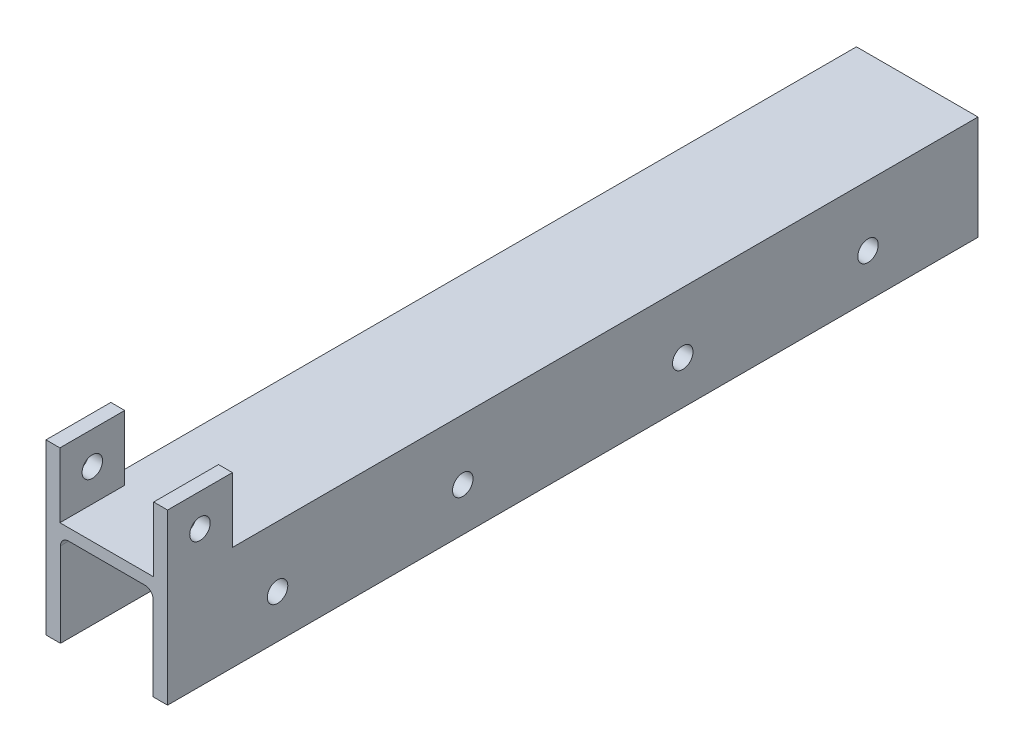
from build123d import *

# Parameters (mm, degrees)
BOSS_EXTRUDE2_DEPTH     = 177.8
SKETCH19_R              = 2.2479
CUT_EXTRUDE3_DEPTH      = 27.67
SKETCH21_W              = 3.048
SKETCH21_H              = 14.224
BOSS_EXTRUDE4_DEPTH     = 14.224
SKETCH22_R              = 2.2479
CUT_EXTRUDE4_DEPTH      = 24.622
CUT_EXTRUDE4_DEPTH_BACK = 4.048


with BuildPart() as part:
    # Sketch2 → Boss-Extrude2 (new body)
    with BuildSketch(Plane.XY):
        with BuildLine():
            Line((0, 0), (0, 22.86))
            Line((0, 22.86), (26.67, 22.86))
            Line((26.67, 22.86), (26.67, 0))
            Line((26.67, 0), (23.495, 0))
            Line((23.495, 0), (23.495, 18.542))
            ThreePointArc((23.495, 18.542), (22.974235857, 19.799235857), (21.717, 20.32))
            Line((21.717, 20.32), (4.953, 20.32))
            ThreePointArc((4.953, 20.32), (3.695764143, 19.799235857), (3.175, 18.542))
            Line((3.175, 18.542), (3.175, 0))
            Line((3.175, 0), (0, 0))
        make_face()
    extrude(amount=-BOSS_EXTRUDE2_DEPTH)

    # Sketch19 → Cut-Extrude3 (cut, through all)
    with BuildSketch(Plane(origin=(0, 0, 0), x_dir=(0, 0, -1), z_dir=(1, 0, 0))):
        with Locations((24.13, 9.525)):
            Circle(SKETCH19_R)
        with Locations((64.77, 9.525)):
            Circle(SKETCH19_R)
        with Locations((113.03, 9.525)):
            Circle(SKETCH19_R)
        with Locations((153.67, 9.525)):
            Circle(SKETCH19_R)
    extrude(amount=CUT_EXTRUDE3_DEPTH, mode=Mode.SUBTRACT)

    # Sketch21 → Boss-Extrude4 (add)
    with BuildSketch(Plane(origin=(0, 22.86, 0), x_dir=(1, 0, 0), z_dir=(0, 1, 0))):
        with Locations((1.524, 7.112)):
            Rectangle(SKETCH21_W, SKETCH21_H)
        with Locations((25.146, 7.112)):
            Rectangle(SKETCH21_W, SKETCH21_H)
    extrude(amount=BOSS_EXTRUDE4_DEPTH)

    # Sketch22 → Cut-Extrude4 (cut, two sides)
    with BuildSketch(Plane.ZY.offset(-23.622)) as cut_extrude4_sk:
        with Locations((-7.112, 29.972)):
            Circle(SKETCH22_R)
    extrude(amount=CUT_EXTRUDE4_DEPTH, mode=Mode.SUBTRACT)
    extrude(cut_extrude4_sk.sketch, amount=-CUT_EXTRUDE4_DEPTH_BACK, mode=Mode.SUBTRACT)


solid = part.part
